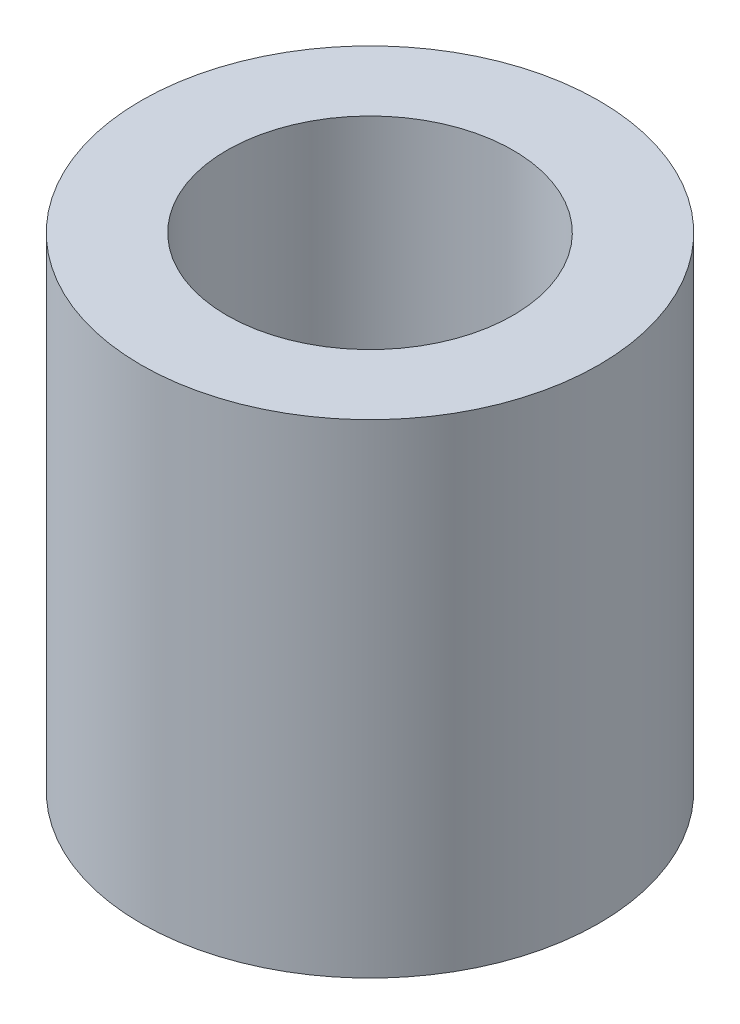
from build123d import *

# Parameters (mm, degrees)
SKETCH1_R           = 4
SKETCH1_R_2         = 2.5
BOSS_EXTRUDE1_DEPTH = 8.45


with BuildPart() as part:
    # Sketch1 → Boss-Extrude1 (new body)
    with BuildSketch(Plane(origin=(0, 0, 0), x_dir=(1, 0, 0), z_dir=(0, 1, 0))):
        Circle(SKETCH1_R)
        Circle(SKETCH1_R_2, mode=Mode.SUBTRACT)
    extrude(amount=BOSS_EXTRUDE1_DEPTH)


solid = part.part
